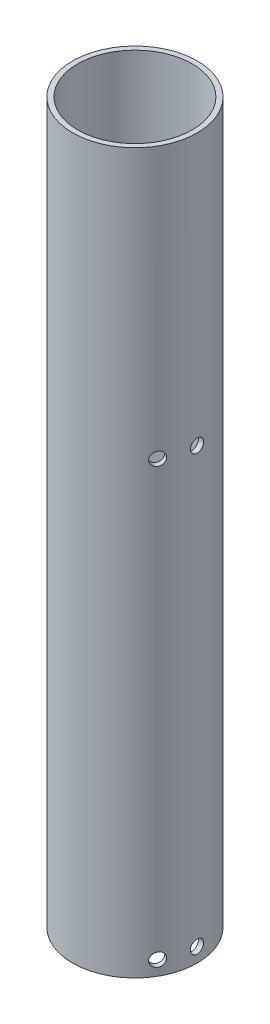
from build123d import *

# Parameters (mm, degrees)
SKETCH1_R               = 26
SKETCH1_R_2             = 23.9
BOSS_EXTRUDE1_DEPTH     = 300
SKETCH3_R               = 2.75
CUT_EXTRUDE2_DEPTH      = 27
CIRPATTERN1_COUNT       = 3
SKETCH5_R               = 2.75
CUT_EXTRUDE3_DEPTH      = 27.0000001
CUT_EXTRUDE3_DEPTH_BACK = 27.0000001


with BuildPart() as part:
    # Sketch1 → Boss-Extrude1 (new body)
    with BuildSketch(Plane(origin=(0, 0, 0), x_dir=(1, 0, 0), z_dir=(0, 1, 0))):
        Circle(SKETCH1_R)
        Circle(SKETCH1_R_2, mode=Mode.SUBTRACT)
    extrude(amount=BOSS_EXTRUDE1_DEPTH)

    # Sketch3 → Cut-Extrude2 (cut, through all)
    with BuildSketch(Plane.XY):
        with Locations((0, 6)):
            Circle(SKETCH3_R)
        with Locations((0, 187)):
            Circle(SKETCH3_R)
    cut_extrude2 = extrude(amount=-CUT_EXTRUDE2_DEPTH, mode=Mode.SUBTRACT)

    # CirPattern1: Cut-Extrude2 ×3 about axis
    cirpattern1_axis = Axis((0, 300, 0), (0, -1, 0))
    for i in range(1, CIRPATTERN1_COUNT):
        add(cut_extrude2.rotate(cirpattern1_axis, i * 360 / CIRPATTERN1_COUNT), mode=Mode.SUBTRACT)

    # Sketch5 → Cut-Extrude3 (cut, two sides)
    with BuildSketch(Plane(origin=(0, 0, 0), x_dir=(0, 0, -1), z_dir=(1, 0, 0))) as cut_extrude3_sk:
        with Locations((0, 187)):
            Circle(SKETCH5_R)
        with Locations((0, 6)):
            Circle(SKETCH5_R)
    extrude(amount=CUT_EXTRUDE3_DEPTH, mode=Mode.SUBTRACT)
    extrude(cut_extrude3_sk.sketch, amount=-CUT_EXTRUDE3_DEPTH_BACK, mode=Mode.SUBTRACT)


solid = part.part
